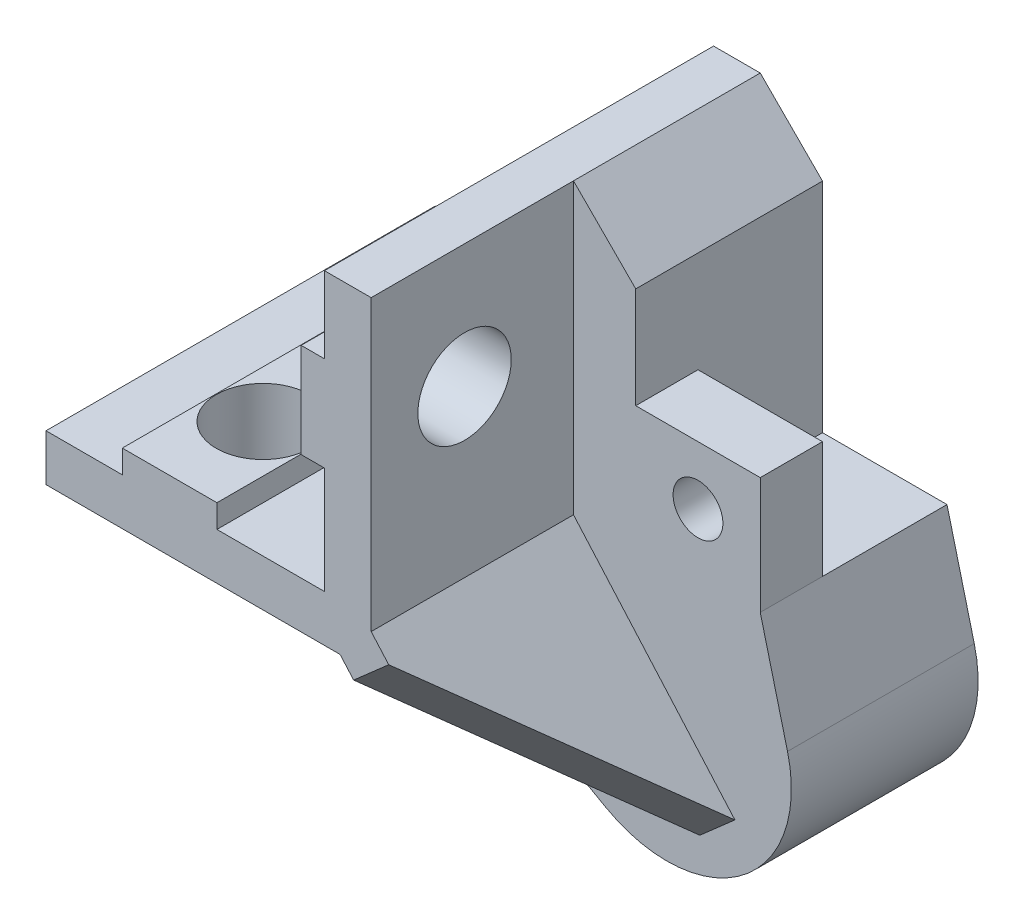
from build123d import *

# Parameters (mm, degrees)
BOSS_EXTRUDE1_DEPTH = 25
SKETCH2_R           = 3
CUT_EXTRUDE1_DEPTH  = 15
SKETCH3_R           = 3
CUT_EXTRUDE2_DEPTH  = 15
BOSS_EXTRUDE2_DEPTH = 12
BOSS_EXTRUDE4_DEPTH = 1.5
SKETCH6_R           = 4.85
CUT_EXTRUDE3_DEPTH  = 9
SKETCH7_W           = 8
SKETCH7_H           = 7.5
BOSS_EXTRUDE5_DEPTH = 4
SKETCH8_R           = 1.6
CUT_EXTRUDE4_DEPTH  = 4


with BuildPart() as part:
    # Sketch1 → Boss-Extrude1 (new body)
    with BuildSketch(Plane.XY):
        Polygon((227.088719843, 62.282971172), (227.088719843, 57.379571172), (225.590119843, 57.379571172), (225.590119843, 51.299571172), (227.088719843, 51.299571172), (227.088719843, 44.429550862), (220.178702595, 44.429550862), (220.178702595, 45.917195068), (214.098687419, 45.917195068), (214.098687419, 44.429550862), (209.19527518, 44.429550862), (209.19527518, 41.429550862), (230.088719843, 41.429550862), (230.088719843, 62.282971172), align=None)
    extrude(amount=-BOSS_EXTRUDE1_DEPTH)

    # Sketch2 → Cut-Extrude1 (cut)
    with BuildSketch(Plane(origin=(230.088719843, 0, 0), x_dir=(0, 0, -1), z_dir=(1, 0, 0))):
        with Locations((6, 54.339571172)):
            Circle(SKETCH2_R)
    extrude(amount=-CUT_EXTRUDE1_DEPTH, mode=Mode.SUBTRACT)

    # Sketch3 → Cut-Extrude2 (cut)
    with BuildSketch(Plane.XZ.offset(-41.429550862)):
        with Locations((217.138695007, -6)):
            Circle(SKETCH3_R)
    extrude(amount=-CUT_EXTRUDE2_DEPTH, mode=Mode.SUBTRACT)

    # Sketch4 → Boss-Extrude2 (add)
    with BuildSketch(Plane(origin=(0, 0, -25), x_dir=(-1, 0, 0), z_dir=(0, 0, -1))):
        with BuildLine():
            Line((-230.088719843, 62.282971172), (-234.088719843, 58.269609721))
            Line((-234.088719843, 58.269609721), (-234.088719843, 44.269609721))
            Line((-234.088719843, 44.269609721), (-242.088719843, 44.269609721))
            Line((-242.088719843, 44.269609721), (-243.840170155, 37.408191323))
            ThreePointArc((-243.840170155, 37.408191323), (-240.951322195, 29.07698458), (-232.154834185, 28.463594817))
            Line((-232.154834185, 28.463594817), (-209.19527518, 41.429550862))
            Line((-209.19527518, 41.429550862), (-230.088719843, 41.429550862))
            Line((-230.088719843, 41.429550862), (-230.088719843, 62.282971172))
        make_face()
    extrude(amount=-BOSS_EXTRUDE2_DEPTH)

    # Sketch5 → Boss-Extrude4 (add, symmetric)
    with BuildSketch(Plane(origin=(150.295838672, 132.167186427, 0), x_dir=(0.660365554, -0.750944296, 0), z_dir=(-0.750944296, -0.660365554, 0))):
        Polygon((120.831380003, -13), (134.831380003, -13), (120.831380003, 0), (116.597450455, 0), (116.597450455, -13), align=None)
    extrude(amount=BOSS_EXTRUDE4_DEPTH, both=True)

    # Sketch6 → Cut-Extrude3 (cut)
    with BuildSketch(Plane(origin=(0, 0, -25), x_dir=(-1, 0, 0), z_dir=(0, 0, -1))):
        with Locations((-236.088719843, 35.429550862)):
            Circle(SKETCH6_R)
    extrude(amount=-CUT_EXTRUDE3_DEPTH, mode=Mode.SUBTRACT)

    # Sketch7 → Boss-Extrude5 (add)
    with BuildSketch(Plane.XY.offset(-13)):
        with Locations((238.088719843, 48.019609721)):
            Rectangle(SKETCH7_W, SKETCH7_H)
    extrude(amount=-BOSS_EXTRUDE5_DEPTH)

    # Sketch8 → Cut-Extrude4 (cut)
    with BuildSketch(Plane.XY.offset(-13)):
        with Locations((238.088719843, 48.019609721)):
            Circle(SKETCH8_R)
    extrude(amount=-CUT_EXTRUDE4_DEPTH, mode=Mode.SUBTRACT)


solid = part.part
